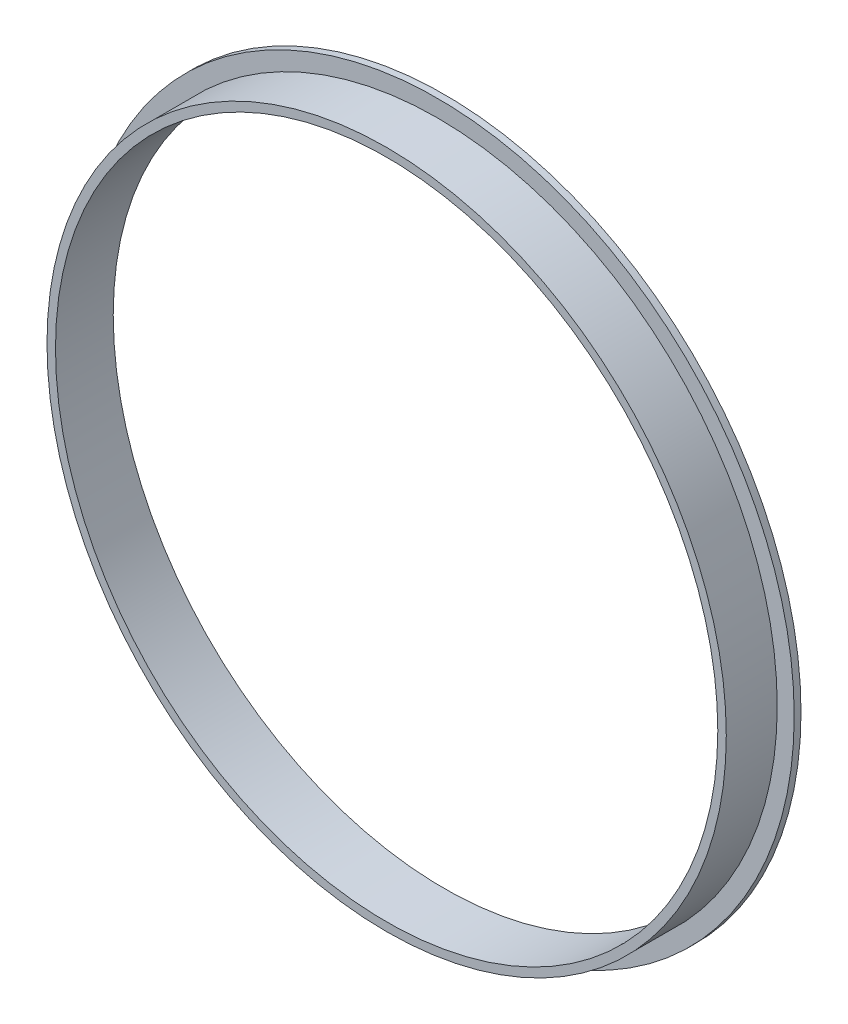
from build123d import *

# Parameters (mm, degrees)
CROQUIS1_R              = 21
SALIENTE_EXTRUIR1_DEPTH = 0.4
CROQUIS2_R              = 20
SALIENTE_EXTRUIR2_DEPTH = 3
CROQUIS3_R              = 19.5
CORTAR_EXTRUIR1_DEPTH   = 4.4


with BuildPart() as part:
    # Croquis1 → Saliente-Extruir1 (new body)
    with BuildSketch(Plane.XY):
        Circle(CROQUIS1_R)
    extrude(amount=SALIENTE_EXTRUIR1_DEPTH)

    # Croquis2 → Saliente-Extruir2 (add)
    with BuildSketch(Plane.XY.offset(0.4)):
        Circle(CROQUIS2_R)
    extrude(amount=SALIENTE_EXTRUIR2_DEPTH)

    # Croquis3 → Cortar-Extruir1 (cut, through all)
    with BuildSketch(Plane.XY.offset(3.4)):
        Circle(CROQUIS3_R)
    extrude(amount=-CORTAR_EXTRUIR1_DEPTH, mode=Mode.SUBTRACT)


solid = part.part
